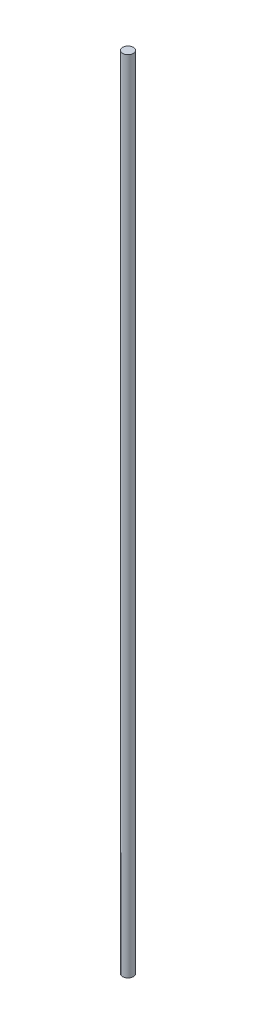
from build123d import *

# Parameters (mm, degrees)
SKETCH_1_W = 2
SKETCH_1_H = 300


with BuildPart() as part:
    # 草图1 → 旋转1 (revolve)
    with BuildSketch(Plane(origin=(0, 0, 0), x_dir=(-1, 0, 0), z_dir=(0, 0, -1))):
        with Locations((-201, -150)):
            Rectangle(SKETCH_1_W, SKETCH_1_H)
    revolve(axis=Axis((200, -300, 0), (0, 1, 0)))


solid = part.part
